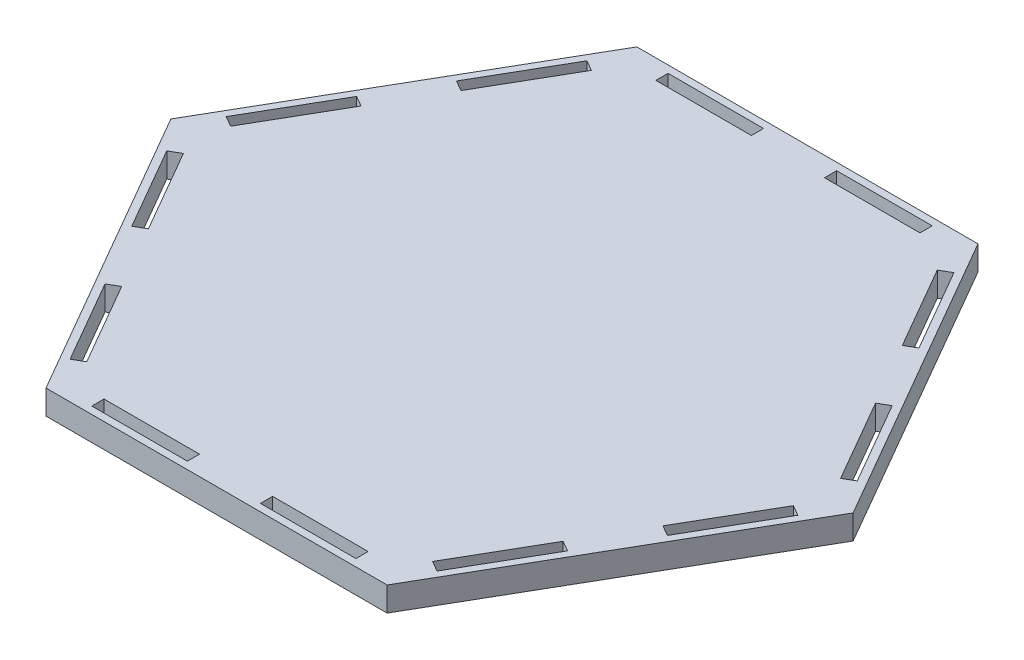
from build123d import *

# Parameters (mm, degrees)
BOSS_EXTRUDE1_DEPTH = 6.35
SKETCH2_W           = 24.892
SKETCH2_H           = 3.175
CUT_EXTRUDE1_DEPTH  = 7.35


with BuildPart() as part:
    # Sketch1 → Boss-Extrude1 (new body)
    with BuildSketch(Plane(origin=(0, 0, 0), x_dir=(1, 0, 0), z_dir=(0, 1, 0))):
        Polygon((-88.9, 0), (-44.45, -76.989658396), (44.45, -76.989658396), (88.9, 0), (44.45, 76.989658396), (-44.45, 76.989658396), align=None)
    extrude(amount=BOSS_EXTRUDE1_DEPTH)

    # Sketch2 → Cut-Extrude1 (cut, through all)
    with BuildSketch(Plane(origin=(0, 6.35, 0), x_dir=(1, 0, 0), z_dir=(0, 1, 0))):
        Polygon((-79.484090949, -6.148832876), (-82.233721606, -7.736332876), (-69.787721606, -29.293437227), (-67.038090949, -27.705937227), align=None)
        Polygon((-45.067090949, -65.76082552), (-47.816721606, -67.34832552), (-60.262721606, -45.791221169), (-57.513090949, -44.203721169), align=None)
        Polygon((-45.067090949, 65.76082552), (-47.816721606, 67.34832552), (-60.262721606, 45.791221169), (-57.513090949, 44.203721169), align=None)
        Polygon((-69.787721606, 29.293437227), (-67.038090949, 27.705937227), (-79.484090949, 6.148832876), (-82.233721606, 7.736332876), align=None)
        with Locations((21.971, 73.497158396)):
            Rectangle(SKETCH2_W, SKETCH2_H)
        with Locations((-21.971, 73.497158396)):
            Rectangle(SKETCH2_W, SKETCH2_H)
        Polygon((79.484090949, 6.148832876), (82.233721606, 7.736332876), (69.787721606, 29.293437227), (67.038090949, 27.705937227), align=None)
        Polygon((60.262721606, 45.791221169), (57.513090949, 44.203721169), (45.067090949, 65.76082552), (47.816721606, 67.34832552), align=None)
        Polygon((45.067090949, -65.76082552), (47.816721606, -67.34832552), (60.262721606, -45.791221169), (57.513090949, -44.203721169), align=None)
        Polygon((69.787721606, -29.293437227), (67.038090949, -27.705937227), (79.484090949, -6.148832876), (82.233721606, -7.736332876), align=None)
        with Locations((-21.971, -73.497158396)):
            Rectangle(SKETCH2_W, SKETCH2_H)
        with Locations((21.971, -73.497158396)):
            Rectangle(SKETCH2_W, SKETCH2_H)
    extrude(amount=-CUT_EXTRUDE1_DEPTH, mode=Mode.SUBTRACT)


solid = part.part
